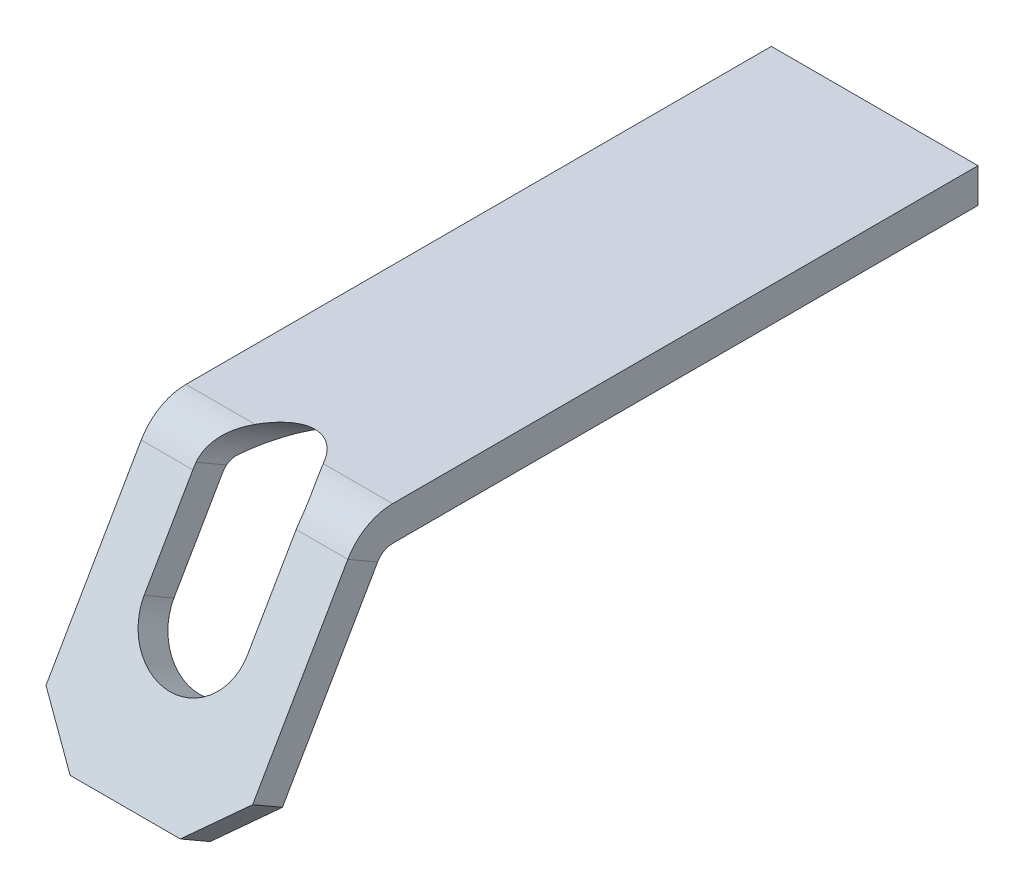
from build123d import *

# Parameters (mm, degrees)
SKETCH1_W           = 3
SKETCH1_H           = 8.5
BOSS_EXTRUDE1_DEPTH = 0.25
SKETCH4_W           = 3
SKETCH4_H           = 0.5
CUT_EXTRUDE1_DEPTH  = 10.548715932
CHAMFER1_SIZE       = 0.7


with BuildPart() as part:
    # Sketch1 → Boss-Extrude1 (new body, symmetric)
    with BuildSketch(Plane(origin=(0, 0, 0), x_dir=(1, 0, 0), z_dir=(0, 1, 0))):
        Rectangle(SKETCH1_W, SKETCH1_H)
    extrude(amount=BOSS_EXTRUDE1_DEPTH, both=True)

    # Sweep1: sweep along a path in Sketch5
    with BuildLine(Plane(origin=(0, 0, 0), x_dir=(0, 0, -1), z_dir=(1, 0, 0))) as sweep1_path:
        Line((-6.415063509, -3.25), (-4.683012702, -0.25))
        ThreePointArc((-4.683012702, -0.25), (-4.5, -0.066987298), (-4.25, 0))
    # Sketch4 → Sweep1 (sweep)
    with BuildSketch(Plane.XY.offset(4.25)):
        Rectangle(SKETCH4_W, SKETCH4_H)
    sweep(path=sweep1_path.line)

    # Sketch6 → Cut-Extrude1 (cut, through all)
    with BuildSketch(Plane(origin=(0, 2.090303983, 3.620512702), x_dir=(1, 0, 0), z_dir=(0, 0.5, 0.866025404))):
        with BuildLine():
            Line((0.75, -2.472114317), (0.75, -3.972114317))
            ThreePointArc((0.75, -3.972114317), (0, -4.722114317), (-0.75, -3.972114317))
            Line((-0.75, -3.972114317), (-0.75, -2.472114317))
            ThreePointArc((-0.75, -2.472114317), (0, -1.722114317), (0.75, -2.472114317))
        make_face()
    extrude(amount=-CUT_EXTRUDE1_DEPTH, mode=Mode.SUBTRACT)

    # Chamfer1
    chamfer1_edges = [part.edges().sort_by_distance(p)[0] for p in [
        (-1.5, -3.25, 6.415063509),
        (1.5, -3.25, 6.415063509),
    ]]
    chamfer(chamfer1_edges, length=CHAMFER1_SIZE)


solid = part.part
